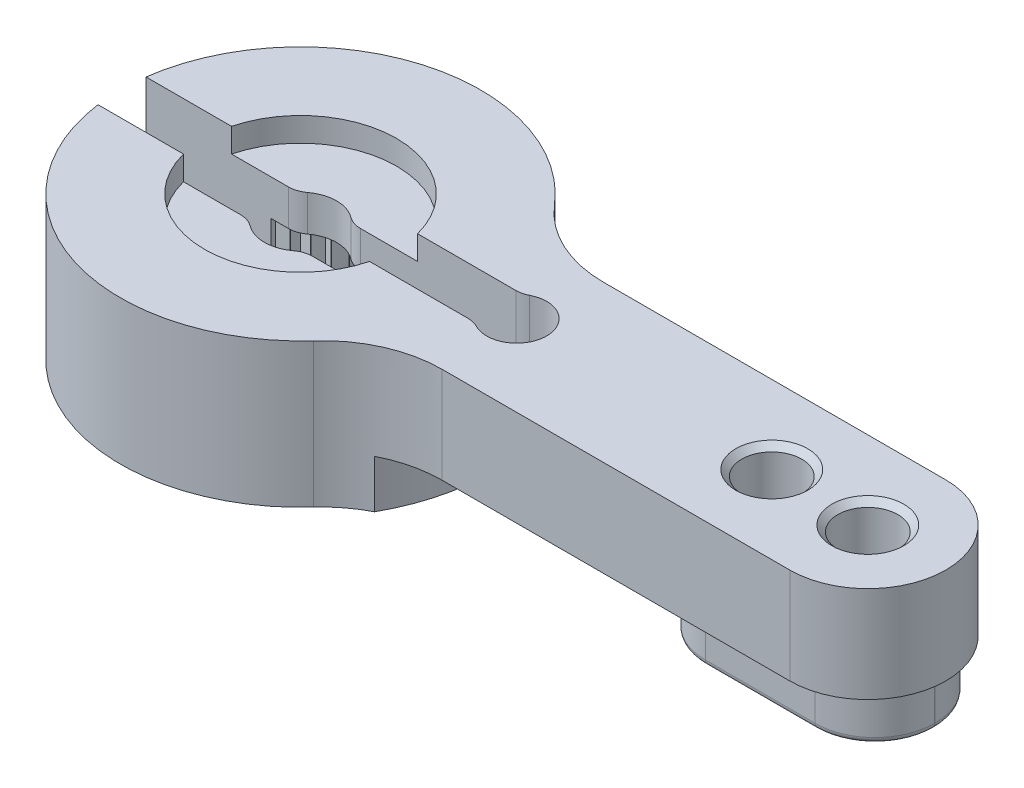
from build123d import *

# Parameters (mm, degrees)
BOSS_EXTRUDE1_DEPTH = 3
SKETCH2_R           = 1.25
CUT_EXTRUDE1_DEPTH  = 16
CHAMFER1_SIZE       = 0.25
SKETCH3_R           = 4
CUT_EXTRUDE2_DEPTH  = 1
CUT_EXTRUDE3_DEPTH  = 11
CUT_EXTRUDE4_DEPTH  = 2
FILLET1_R           = 0.25
CUT_EXTRUDE5_DEPTH  = 3
SKETCH7_R           = 2.35
CUT_EXTRUDE6_DEPTH  = 3.5
CUT_EXTRUDE7_DEPTH  = 3.5
CIRPATTERN1_COUNT   = 24


with BuildPart() as part:
    # Sketch1 → Boss-Extrude1 (new body, symmetric)
    with BuildSketch(Plane(origin=(0, 0, 0), x_dir=(1, 0, 0), z_dir=(0, 1, 0))):
        with BuildLine():
            Line((23.75, 3.122009569), (9.501734608, 3.122009569))
            ThreePointArc((9.501734608, 3.122009569), (7.409369814, 3.580863286), (5.701040765, 4.873205742))
            ThreePointArc((5.701040765, 4.873205742), (-7.499303275, 0.102227183), (5.566088347, -5.026794258))
            ThreePointArc((5.566088347, -5.026794258), (7.246540637, -3.808746464), (9.276813911, -3.377990431))
            Line((9.276813911, -3.377990431), (23.75, -3.377990431))
            ThreePointArc((23.75, -3.377990431), (27, -0.127990431), (23.75, 3.122009569))
        make_face()
    extrude(amount=BOSS_EXTRUDE1_DEPTH, both=True)

    # Sketch2 → Cut-Extrude1 (cut)
    with BuildSketch(Plane(origin=(0, 3, 0), x_dir=(1, 0, 0), z_dir=(0, 1, 0))):
        with Locations((23.75, -0.127990431)):
            Circle(SKETCH2_R)
        with Locations((19.75, -0.127990431)):
            Circle(SKETCH2_R)
    extrude(amount=-CUT_EXTRUDE1_DEPTH, mode=Mode.SUBTRACT)

    # Chamfer1
    chamfer1_edges = [part.edges().sort_by_distance(p)[0] for p in [
        (22.5, 3, 0.127990431),
        (18.5, 3, 0.127990431),
    ]]
    chamfer(chamfer1_edges, length=CHAMFER1_SIZE)

    # Sketch3 → Cut-Extrude2 (cut)
    with BuildSketch(Plane(origin=(0, 3, 0), x_dir=(1, 0, 0), z_dir=(0, 1, 0))):
        Circle(SKETCH3_R)
    extrude(amount=-CUT_EXTRUDE2_DEPTH, mode=Mode.SUBTRACT)

    # Sketch4 → Cut-Extrude3 (cut)
    with BuildSketch(Plane(origin=(0, 3, 0), x_dir=(1, 0, 0), z_dir=(0, 1, 0))):
        with BuildLine():
            Line((-1.5, 1), (-9, 1))
            Line((-9, 1), (-9, -1))
            Line((-9, -1), (-1.5, -1))
            ThreePointArc((-1.5, -1), (-1.183772234, -1.051316702), (-0.9, -1.2))
            ThreePointArc((-0.9, -1.2), (0, -1.5), (0.9, -1.2))
            ThreePointArc((0.9, -1.2), (1.183772234, -1.051316702), (1.5, -1))
            Line((1.5, -1), (7.969223594, -1))
            ThreePointArc((7.969223594, -1), (8.204925854, -1.028174684), (8.427346441, -1.111111111))
            ThreePointArc((8.427346441, -1.111111111), (10.25, 0), (8.427346441, 1.111111111))
            ThreePointArc((8.427346441, 1.111111111), (8.204925854, 1.028174684), (7.969223594, 1))
            Line((7.969223594, 1), (1.5, 1))
            ThreePointArc((1.5, 1), (1.183772234, 1.051316702), (0.9, 1.2))
            ThreePointArc((0.9, 1.2), (0, 1.5), (-0.9, 1.2))
            ThreePointArc((-0.9, 1.2), (-1.183772234, 1.051316702), (-1.5, 1))
        make_face()
    extrude(amount=-CUT_EXTRUDE3_DEPTH, mode=Mode.SUBTRACT)

    # Sketch5 → Cut-Extrude4 (cut)
    with BuildSketch(Plane.XZ.offset(3)):
        with BuildLine():
            Line((24.055684797, -4.372009569), (19.49, -4.372009569))
            Line((19.49, -4.372009569), (6.737511188, -4.372009569))
            ThreePointArc((6.737511188, -4.372009569), (8.030233116, 0.154534121), (6.564314835, 4.627990431))
            Line((6.564314835, 4.627990431), (19.49, 4.627990431))
            Line((19.49, 4.627990431), (24.055684797, 4.627990431))
            ThreePointArc((24.055684797, 4.627990431), (27.230594245, 3.312899878), (28.545684797, 0.137990431))
            Line((28.545684797, 0.137990431), (28.545684797, 0.117990431))
            ThreePointArc((28.545684797, 0.117990431), (27.230594245, -3.056919017), (24.055684797, -4.372009569))
        make_face()
        with BuildLine():
            Line((24.055684797, 2.627990431), (19.49, 2.627990431))
            ThreePointArc((19.49, 2.627990431), (17.729304115, 1.898686316), (17, 0.137990431))
            Line((17, 0.137990431), (17, 0.117990431))
            ThreePointArc((17, 0.117990431), (17.729304115, -1.642705455), (19.49, -2.372009569))
            Line((19.49, -2.372009569), (24.055684797, -2.372009569))
            ThreePointArc((24.055684797, -2.372009569), (25.816380683, -1.642705455), (26.545684797, 0.117990431))
            Line((26.545684797, 0.117990431), (26.545684797, 0.137990431))
            ThreePointArc((26.545684797, 0.137990431), (25.816380683, 1.898686316), (24.055684797, 2.627990431))
        make_face(mode=Mode.SUBTRACT)
    extrude(amount=-CUT_EXTRUDE4_DEPTH, mode=Mode.SUBTRACT)

    # Fillet1
    fillet1_edges = [part.edges().sort_by_distance(p)[0] for p in [
        (25.816380683, -3, -1.642705455),
        (21.772842399, -3, -2.372009569),
        (17.729304115, -3, -1.642705455),
        (17, -3, 0.127990431),
        (17.729304115, -3, 1.898686316),
        (21.772842399, -3, 2.627990431),
        (25.816380683, -3, 1.898686316),
        (26.545684797, -3, 0.127990431),
    ]]
    fillet(fillet1_edges, radius=FILLET1_R)

    # Sketch6 → Cut-Extrude5 (cut)
    with BuildSketch(Plane.XZ.offset(1)):
        with BuildLine():
            Line((16.572326108, 2.507990431), (10.678705054, 2.507990431))
            Line((10.678705054, 2.507990431), (9.432782088, 2.507990431))
            ThreePointArc((9.432782088, 2.507990431), (10.490779488, -0.069105379), (8.754910472, -2.247990431))
            Line((8.754910472, -2.247990431), (10.678705054, -2.247990431))
            Line((10.678705054, -2.247990431), (16.572326108, -2.247990431))
            Line((16.572326108, -2.247990431), (18.365364688, -2.247990431))
            ThreePointArc((18.365364688, -2.247990431), (17.000002911, 0.131991595), (18.3722845, 2.507990431))
            Line((18.3722845, 2.507990431), (16.572326108, 2.507990431))
        make_face()
    extrude(amount=-CUT_EXTRUDE5_DEPTH, mode=Mode.SUBTRACT)

    # Sketch7 → Cut-Extrude6 (cut)
    with BuildSketch(Plane.XZ.offset(3)):
        Circle(SKETCH7_R)
    extrude(amount=-CUT_EXTRUDE6_DEPTH, mode=Mode.SUBTRACT)

    # Sketch8 → Cut-Extrude7 (cut)
    with BuildSketch(Plane.XZ.offset(3)):
        with BuildLine():
            ThreePointArc((-0.299151371, 2.330881476), (0, 2.35), (0.299151371, 2.330881476))
            Line((0.299151371, 2.330881476), (0, 2.84902685))
            Line((0, 2.84902685), (-0.299151371, 2.330881476))
        make_face()
    cut_extrude7 = extrude(amount=-CUT_EXTRUDE7_DEPTH, mode=Mode.SUBTRACT)

    # CirPattern1: Cut-Extrude7 ×24 about axis
    cirpattern1_axis = Axis((0, 0, 0), (0, 1, 0))
    for i in range(1, CIRPATTERN1_COUNT):
        add(cut_extrude7.rotate(cirpattern1_axis, i * 360 / CIRPATTERN1_COUNT), mode=Mode.SUBTRACT)


solid = part.part
